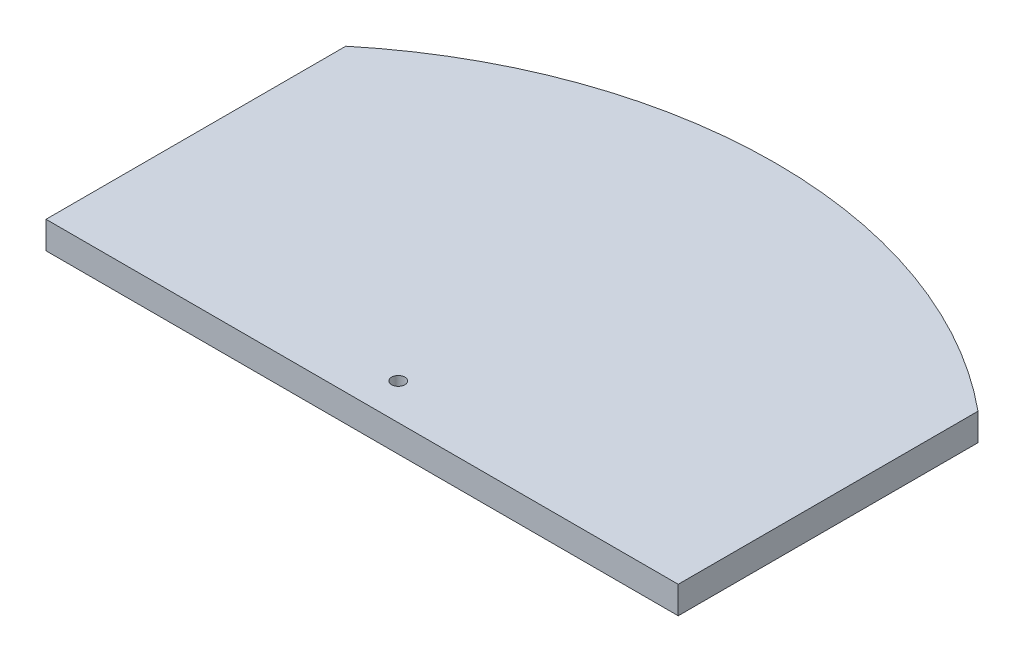
from build123d import *

# Parameters (mm, degrees)
SKETCH1_R           = 1
BOSS_EXTRUDE1_DEPTH = 4.1


with BuildPart() as part:
    # Sketch1 → Boss-Extrude1 (new body)
    with BuildSketch(Plane(origin=(0, 0, 0), x_dir=(1, 0, 0), z_dir=(0, 1, 0))):
        with BuildLine():
            Line((-47.45, -31.685353535), (-47.45, -76.685353535))
            Line((-47.45, -76.685353535), (47.45, -76.685353535))
            Line((47.45, -76.685353535), (47.45, -31.685353535))
            ThreePointArc((47.45, -31.685353535), (0, -14.620077353), (-47.45, -31.685353535))
        make_face()
        with Locations((0, -71.260285785)):
            Circle(SKETCH1_R, mode=Mode.SUBTRACT)
    extrude(amount=BOSS_EXTRUDE1_DEPTH)


solid = part.part
